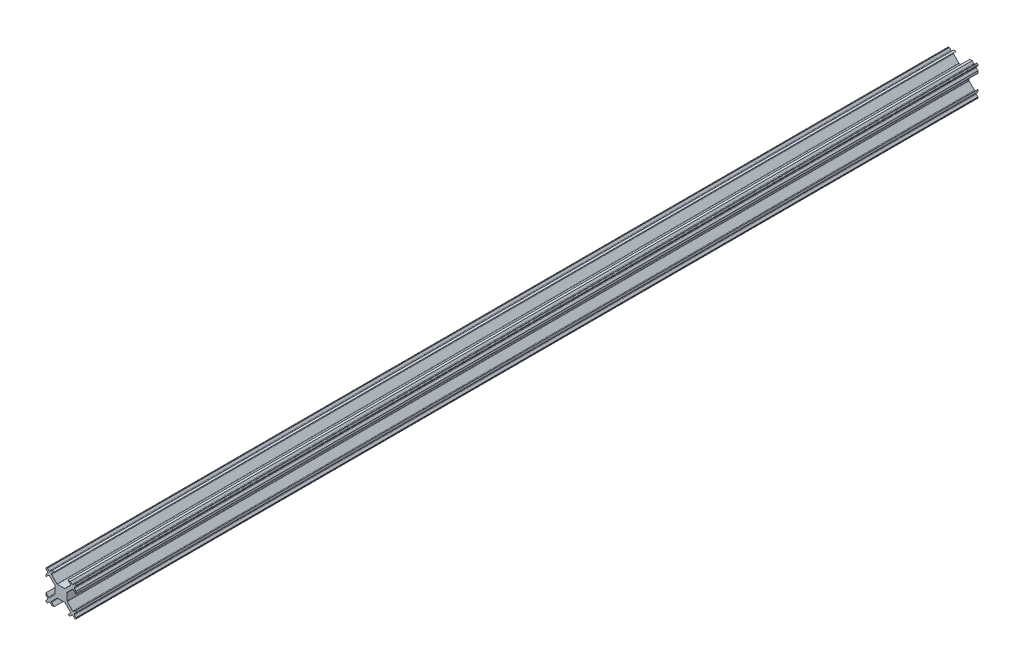
from build123d import *

# Parameters (mm, degrees)
BOSS_EXTRUDE1_DEPTH = 300


with BuildPart() as part:
    # Sketch1 → Boss-Extrude1 (new body)
    with BuildSketch(Plane.XY.offset(12.5)):
        with BuildLine():
            Line((1.189339828, 2), (-1.189339828, 2))
            ThreePointArc((-1.189339828, 2), (-1.285010686, 2.019030117), (-1.366116524, 2.073223305))
            Line((-1.366116524, 2.073223305), (-3.116116524, 3.823223305))
            ThreePointArc((-3.116116524, 3.823223305), (-3.189339828, 4), (-3.116116524, 4.176776695))
            Line((-3.116116524, 4.176776695), (-2.292893219, 5))
            Line((-2.292893219, 5), (-3.094974747, 5))
            Line((-3.094974747, 5), (-3.623223305, 4.471751442))
            ThreePointArc((-3.623223305, 4.471751442), (-3.8, 4.398528137), (-3.976776695, 4.471751442))
            Line((-3.976776695, 4.471751442), (-4.505025253, 5))
            Line((-4.505025253, 5), (-4.75, 5))
            ThreePointArc((-4.75, 5), (-4.926776695, 4.926776695), (-5, 4.75))
            Line((-5, 4.75), (-5, 4.505025253))
            Line((-5, 4.505025253), (-4.471751442, 3.976776695))
            ThreePointArc((-4.471751442, 3.976776695), (-4.398528137, 3.8), (-4.471751442, 3.623223305))
            Line((-4.471751442, 3.623223305), (-5, 3.094974747))
            Line((-5, 3.094974747), (-5, 2.292893219))
            Line((-5, 2.292893219), (-4.176776695, 3.116116524))
            ThreePointArc((-4.176776695, 3.116116524), (-4, 3.189339828), (-3.823223305, 3.116116524))
            Line((-3.823223305, 3.116116524), (-2.073223305, 1.366116524))
            ThreePointArc((-2.073223305, 1.366116524), (-2.019030117, 1.285010686), (-2, 1.189339828))
            Line((-2, 1.189339828), (-2, -1.189339828))
            ThreePointArc((-2, -1.189339828), (-2.019030117, -1.285010686), (-2.073223305, -1.366116524))
            Line((-2.073223305, -1.366116524), (-3.823223305, -3.116116524))
            ThreePointArc((-3.823223305, -3.116116524), (-4, -3.189339828), (-4.176776695, -3.116116524))
            Line((-4.176776695, -3.116116524), (-5, -2.292893219))
            Line((-5, -2.292893219), (-5, -3.094974747))
            Line((-5, -3.094974747), (-4.471751442, -3.623223305))
            ThreePointArc((-4.471751442, -3.623223305), (-4.398528137, -3.8), (-4.471751442, -3.976776695))
            Line((-4.471751442, -3.976776695), (-5, -4.505025253))
            Line((-5, -4.505025253), (-5, -4.75))
            ThreePointArc((-5, -4.75), (-4.926776695, -4.926776695), (-4.75, -5))
            Line((-4.75, -5), (-4.505025253, -5))
            Line((-4.505025253, -5), (-3.976776695, -4.471751442))
            ThreePointArc((-3.976776695, -4.471751442), (-3.8, -4.398528137), (-3.623223305, -4.471751442))
            Line((-3.623223305, -4.471751442), (-3.094974747, -5))
            Line((-3.094974747, -5), (-2.292893219, -5))
            Line((-2.292893219, -5), (-3.116116524, -4.176776695))
            ThreePointArc((-3.116116524, -4.176776695), (-3.189339828, -4), (-3.116116524, -3.823223305))
            Line((-3.116116524, -3.823223305), (-1.366116524, -2.073223305))
            ThreePointArc((-1.366116524, -2.073223305), (-1.285010686, -2.019030117), (-1.189339828, -2))
            Line((-1.189339828, -2), (1.189339828, -2))
            ThreePointArc((1.189339828, -2), (1.285010686, -2.019030117), (1.366116524, -2.073223305))
            Line((1.366116524, -2.073223305), (3.116116524, -3.823223305))
            ThreePointArc((3.116116524, -3.823223305), (3.189339828, -4), (3.116116524, -4.176776695))
            Line((3.116116524, -4.176776695), (2.292893219, -5))
            Line((2.292893219, -5), (3.094974747, -5))
            Line((3.094974747, -5), (3.623223305, -4.471751442))
            ThreePointArc((3.623223305, -4.471751442), (3.8, -4.398528137), (3.976776695, -4.471751442))
            Line((3.976776695, -4.471751442), (4.505025253, -5))
            Line((4.505025253, -5), (4.75, -5))
            ThreePointArc((4.75, -5), (4.926776695, -4.926776695), (5, -4.75))
            Line((5, -4.75), (5, -4.505025253))
            Line((5, -4.505025253), (4.471751442, -3.976776695))
            ThreePointArc((4.471751442, -3.976776695), (4.398528137, -3.8), (4.471751442, -3.623223305))
            Line((4.471751442, -3.623223305), (5, -3.094974747))
            Line((5, -3.094974747), (5, -2.292893219))
            Line((5, -2.292893219), (4.176776695, -3.116116524))
            ThreePointArc((4.176776695, -3.116116524), (4, -3.189339828), (3.823223305, -3.116116524))
            Line((3.823223305, -3.116116524), (2.073223305, -1.366116524))
            ThreePointArc((2.073223305, -1.366116524), (2.019030117, -1.285010686), (2, -1.189339828))
            Line((2, -1.189339828), (2, 1.189339828))
            ThreePointArc((2, 1.189339828), (2.019030117, 1.285010686), (2.073223305, 1.366116524))
            Line((2.073223305, 1.366116524), (3.823223305, 3.116116524))
            ThreePointArc((3.823223305, 3.116116524), (4, 3.189339828), (4.176776695, 3.116116524))
            Line((4.176776695, 3.116116524), (5, 2.292893219))
            Line((5, 2.292893219), (5, 3.094974747))
            Line((5, 3.094974747), (4.471751442, 3.623223305))
            ThreePointArc((4.471751442, 3.623223305), (4.398528137, 3.8), (4.471751442, 3.976776695))
            Line((4.471751442, 3.976776695), (5, 4.505025253))
            Line((5, 4.505025253), (5, 4.75))
            ThreePointArc((5, 4.75), (4.926776695, 4.926776695), (4.75, 5))
            Line((4.75, 5), (4.505025253, 5))
            Line((4.505025253, 5), (3.976776695, 4.471751442))
            ThreePointArc((3.976776695, 4.471751442), (3.8, 4.398528137), (3.623223305, 4.471751442))
            Line((3.623223305, 4.471751442), (3.094974747, 5))
            Line((3.094974747, 5), (2.292893219, 5))
            Line((2.292893219, 5), (3.116116524, 4.176776695))
            ThreePointArc((3.116116524, 4.176776695), (3.189339828, 4), (3.116116524, 3.823223305))
            Line((3.116116524, 3.823223305), (1.366116524, 2.073223305))
            ThreePointArc((1.366116524, 2.073223305), (1.285010686, 2.019030117), (1.189339828, 2))
        make_face()
    extrude(amount=-BOSS_EXTRUDE1_DEPTH)


solid = part.part
